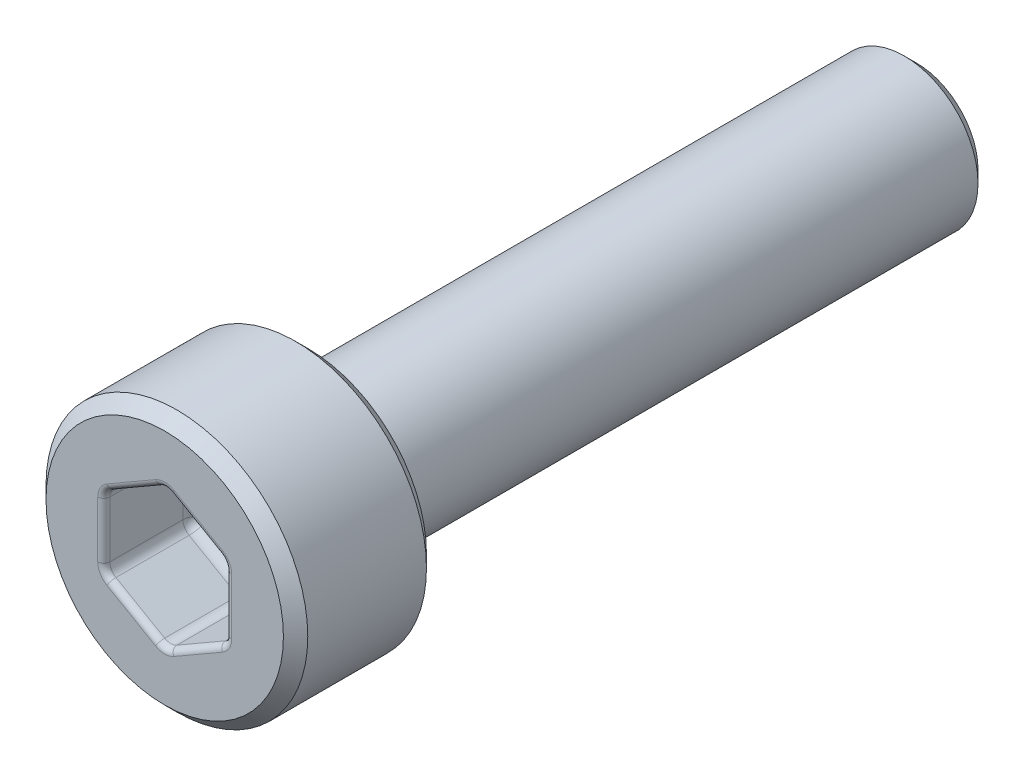
from build123d import *

# Parameters (mm, degrees)
SCHNITT_LINEAR_AUSTRAGEN1_DEPTH = 1.5
FASE1_SIZE                      = 0.2
VERRUNDUNG1_R                   = 0.2
VERRUNDUNG2_R                   = 0.1


with BuildPart() as part:
    # Skizze1 → Rotation1 (revolve)
    with BuildSketch(Plane(origin=(0, 0, 0), x_dir=(0, 0, -1), z_dir=(1, 0, 0))):
        Polygon((-2.35, 0), (-2.35, 2.15), (0, 2.15), (0, 1.21), (10, 1.21), (10, 0), align=None)
    revolve(axis=Axis((0, 0, 21.919879518), (0, 0, -1)))

    # Skizze2 → Schnitt-Linear austragen1 (cut)
    with BuildSketch(Plane.XY.offset(2.35)):
        Polygon((1, -0.577350269), (1, 0.577350269), (0, 1.154700538), (-1, 0.577350269), (-1, -0.577350269), (0, -1.154700538), align=None)
    extrude(amount=-SCHNITT_LINEAR_AUSTRAGEN1_DEPTH, mode=Mode.SUBTRACT)

    # Fase1
    fase1_edges = [part.edges().sort_by_distance(p)[0] for p in [
        (0, -1.21, -10),
        (0, -2.15, 0),
        (0, -2.15, 2.35),
    ]]
    chamfer(fase1_edges, length=FASE1_SIZE)

    # Verrundung1
    verrundung1_edges = [part.edges().sort_by_distance(p)[0] for p in [
        (0.5, -0.866025404, 0.85),
        (1, -0.577350269, 1.6),
        (-0.5, -0.866025404, 0.85),
        (0, -1.154700538, 1.6),
        (-1, 0, 0.85),
        (-1, -0.577350269, 1.6),
        (-0.5, 0.866025404, 0.85),
        (-1, 0.577350269, 1.6),
        (0.5, 0.866025404, 0.85),
        (0, 1.154700538, 1.6),
        (1, 0, 0.85),
        (1, 0.577350269, 1.6),
        (0, -1.21, 0),
    ]]
    fillet(verrundung1_edges, radius=VERRUNDUNG1_R)

    # Verrundung2
    verrundung2_edges = [part.edges().sort_by_distance(p)[0] for p in [
        (-0.5, -0.866025404, 2.35),
        (-1, 0, 2.35),
        (-0.5, 0.866025404, 2.35),
        (0.5, 0.866025404, 2.35),
        (1, 0, 2.35),
        (0.5, -0.866025404, 2.35),
        (-0.973205081, -0.561880215, 2.35),
        (0, -1.123760431, 2.35),
        (0.973205081, -0.561880215, 2.35),
        (0.973205081, 0.561880215, 2.35),
        (0, 1.123760431, 2.35),
        (-0.973205081, 0.561880215, 2.35),
    ]]
    fillet(verrundung2_edges, radius=VERRUNDUNG2_R)


solid = part.part
